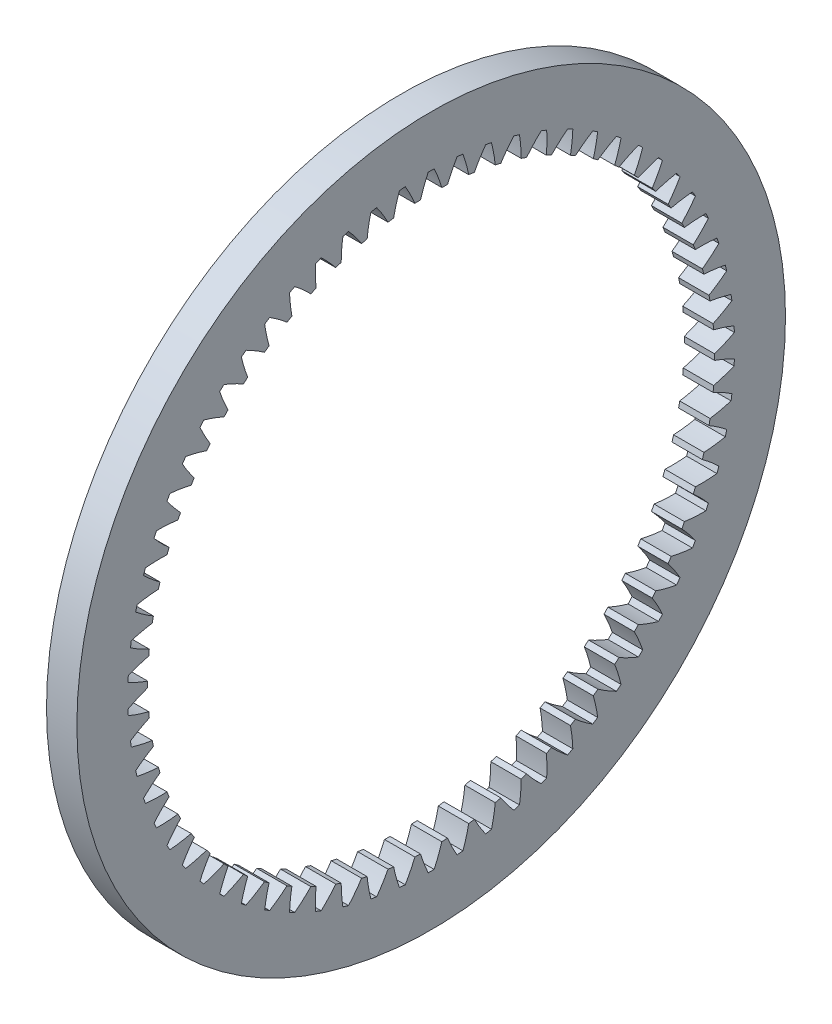
from build123d import *

# Parameters (mm, degrees)
BASPROSKE_W     = 6
BASPROSKE_H     = 14
TOOTHCUT_DEPTH  = 100.176610146
TEETHCUTS_COUNT = 66
TEETHCUTS_ANGLE = 354.545454545


with BuildPart() as part:
    # BasProSke → Base-Revolve (revolve)
    with BuildSketch(Plane(origin=(0, 0, 0), x_dir=(1, 0, 0), z_dir=(0, 1, 0))):
        with Locations((3, 63)):
            Rectangle(BASPROSKE_W, BASPROSKE_H)
    revolve(axis=Axis((-10, 0, 0), (1, 0, 0)))

    # TooCutSke → ToothCut (cut, through all)
    with BuildSketch(Plane(origin=(0, 0, 0), x_dir=(0, 0, -1), z_dir=(1, 0, 0))):
        with BuildLine():
            ThreePointArc((2.107348291, 55.934916898), (1.419046704, 57.963601499), (0.582232555, 59.935672078))
            ThreePointArc((0.582232555, 59.935672078), (0, 59.9385), (-0.582232555, 59.935672078))
            ThreePointArc((-0.582232555, 59.935672078), (-1.419046704, 57.963601499), (-2.107348291, 55.934916898))
            ThreePointArc((-2.107348291, 55.934916898), (0, 55.9746), (2.107348291, 55.934916898))
        make_face()
    toothcut = extrude(amount=TOOTHCUT_DEPTH, mode=Mode.SUBTRACT)

    # TeethCuts: ToothCut ×66 about axis
    teethcuts_axis = Axis((-10, 0, 0), (1, 0, 0))
    for i in range(1, TEETHCUTS_COUNT):
        add(toothcut.rotate(teethcuts_axis, i * TEETHCUTS_ANGLE / (TEETHCUTS_COUNT - 1)), mode=Mode.SUBTRACT)


solid = part.part
